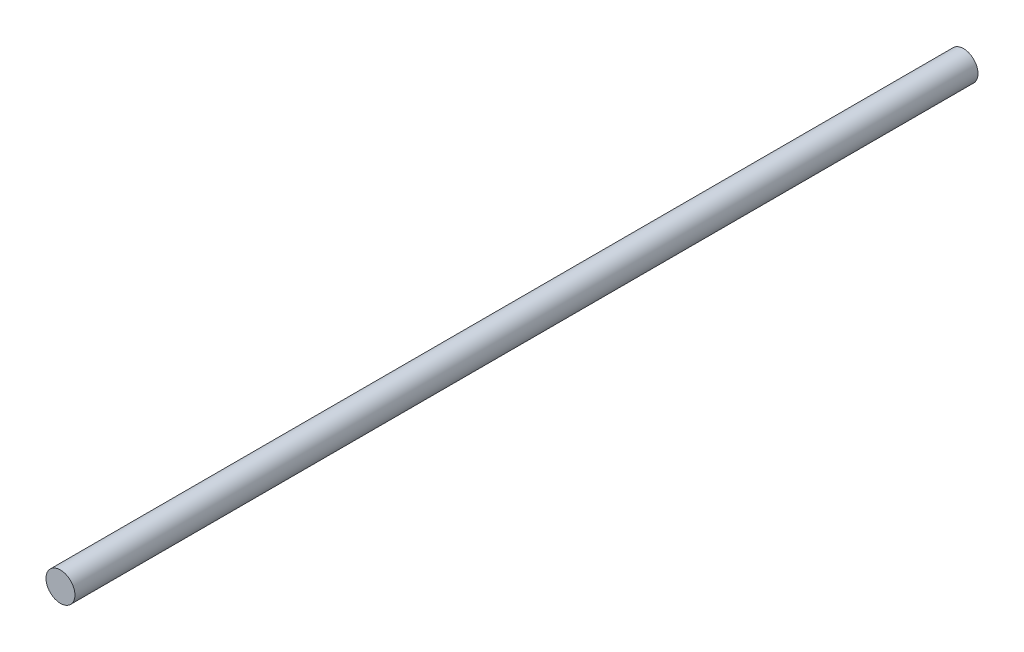
from build123d import *

# Parameters (mm, degrees)
SKETCH1_R           = 0.625
BOSS_EXTRUDE1_DEPTH = 39


with BuildPart() as part:
    # Sketch1 → Boss-Extrude1 (new body)
    with BuildSketch(Plane.XY):
        Circle(SKETCH1_R)
    extrude(amount=BOSS_EXTRUDE1_DEPTH)


solid = part.part
